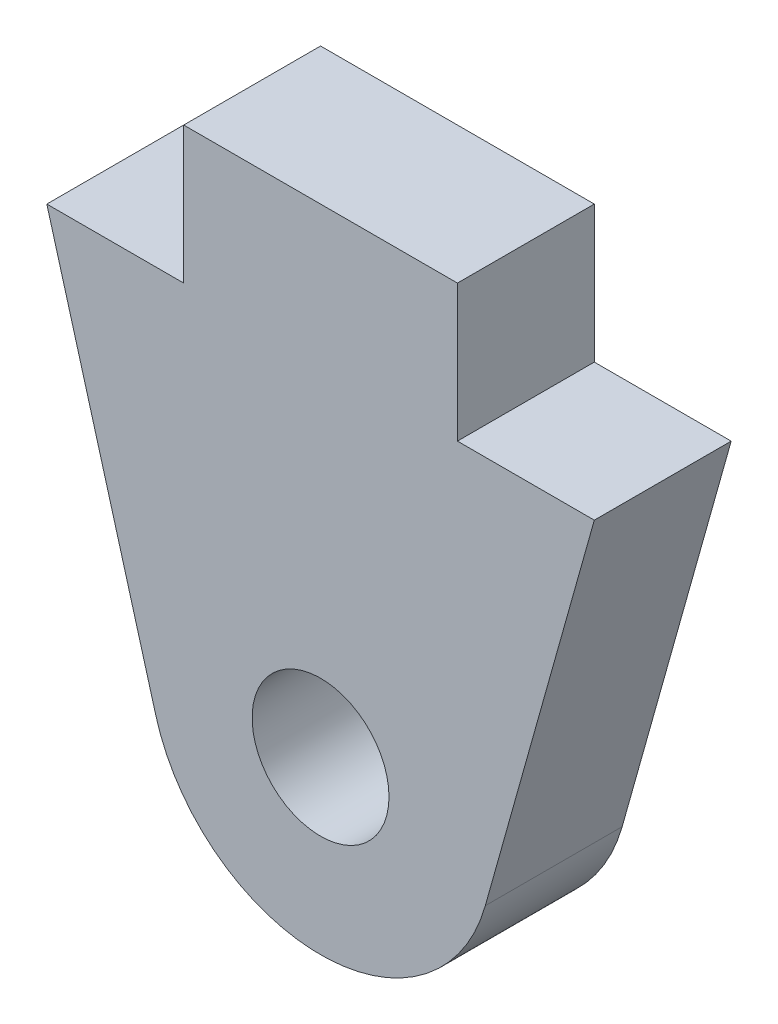
from build123d import *

# Parameters (mm, degrees)
SKETCH1_R           = 3.175
BOSS_EXTRUDE1_DEPTH = 6.35


with BuildPart() as part:
    # Sketch1 → Boss-Extrude1 (new body)
    with BuildSketch(Plane.XY):
        with BuildLine():
            Line((-524.213255123, 3.175), (-536.913255123, 3.175))
            Line((-536.913255123, 3.175), (-536.913255123, -3.175))
            Line((-536.913255123, -3.175), (-543.263255123, -3.175))
            Line((-543.263255123, -3.175), (-538.205434687, -21.194993651))
            ThreePointArc((-538.205434687, -21.194993651), (-530.563255123, -26.9875), (-522.921075559, -21.194993651))
            Line((-522.921075559, -21.194993651), (-517.863255123, -3.175))
            Line((-517.863255123, -3.175), (-524.213255123, -3.175))
            Line((-524.213255123, -3.175), (-524.213255123, 3.175))
        make_face()
        with Locations((-530.563255123, -19.05)):
            Circle(SKETCH1_R, mode=Mode.SUBTRACT)
    extrude(amount=BOSS_EXTRUDE1_DEPTH)


solid = part.part
